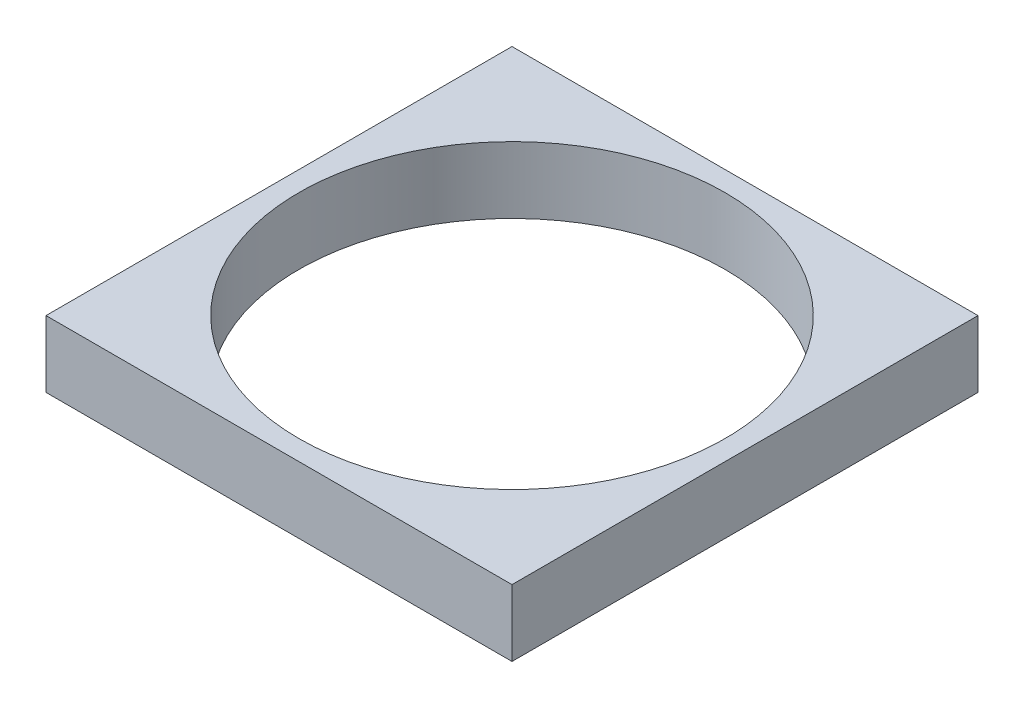
from build123d import *

# Parameters (mm, degrees)
SKETCH1_W           = 70
SKETCH1_H           = 70
SKETCH1_R           = 32.004
BOSS_EXTRUDE1_DEPTH = 10


with BuildPart() as part:
    # Sketch1 → Boss-Extrude1 (new body)
    with BuildSketch(Plane(origin=(0, 0, 0), x_dir=(1, 0, 0), z_dir=(0, 1, 0))):
        Rectangle(SKETCH1_W, SKETCH1_H)
        Circle(SKETCH1_R, mode=Mode.SUBTRACT)
    extrude(amount=BOSS_EXTRUDE1_DEPTH)


solid = part.part
